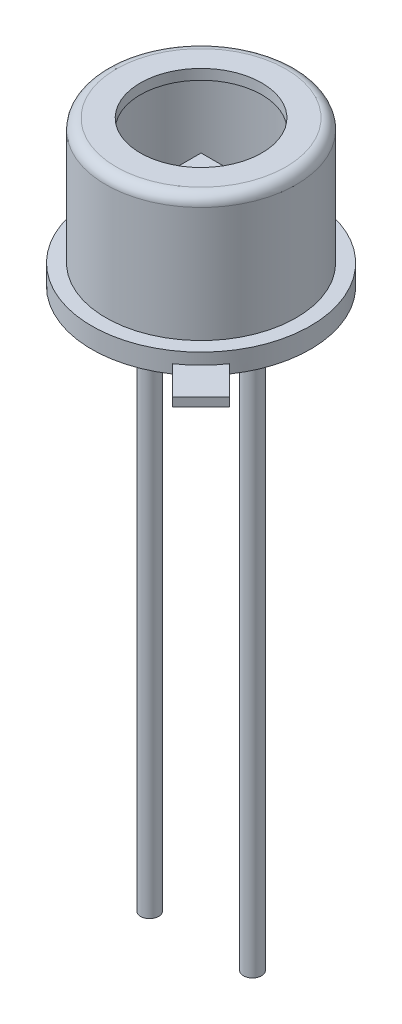
from build123d import *

# Parameters (mm, degrees)
SKETCH2_R           = 2.7
BOSS_EXTRUDE1_DEPTH = 0.246
BOSS_EXTRUDE2_START = -2.3
SKETCH3_W           = 1.1
SKETCH3_H           = 1.1
BOSS_EXTRUDE2_DEPTH = 0.05
BOSS_EXTRUDE7_DEPTH = 0.22
SKETCH5_R           = 0.225
BOSS_EXTRUDE8_DEPTH = 14


with BuildPart() as part:
    # Sketch1 → Revolve-Thin2 (revolve)
    with BuildSketch(Plane.XY):
        with BuildLine():
            Line((2.7, 0), (2.7, 0.5))
            Line((2.7, 0.5), (2.35, 0.5))
            Line((2.35, 0.5), (2.35, 3.346))
            ThreePointArc((2.35, 3.346), (2.275605122, 3.525605122), (2.096, 3.6))
            Line((2.096, 3.6), (1.5, 3.6))
            Line((1.5, 3.6), (1.5, 3.346))
            Line((1.5, 3.346), (2.096, 3.346))
            Line((2.096, 3.346), (2.096, 0.246))
            Line((2.096, 0.246), (2.446, 0.246))
            Line((2.446, 0.246), (2.446, 0))
            Line((2.446, 0), (2.7, 0))
        make_face()
    revolve(axis=Axis((0, 0, 0), (0, 1, 0)))

    # Sketch2 → Boss-Extrude1 (add)
    with BuildSketch(Plane.XZ):
        Circle(SKETCH2_R)
    extrude(amount=-BOSS_EXTRUDE1_DEPTH)

    # Sketch10 → Boss-Extrude7 (add)
    with BuildSketch(Plane.XZ):
        Polygon((1.522612913, 2.229719695), (2.229719695, 1.522612913), (2.936826476, 2.229719695), (2.229719695, 2.936826476), align=None)
    extrude(amount=-BOSS_EXTRUDE7_DEPTH)

    # Sketch5 → Boss-Extrude8 (add)
    with BuildSketch(Plane.XZ):
        with Locations((1.27, 0)):
            Circle(SKETCH5_R)
        with Locations((-1.27, 0)):
            Circle(SKETCH5_R)
    extrude(amount=BOSS_EXTRUDE8_DEPTH)


with BuildPart() as body_2:
    # Sketch3 → Boss-Extrude2 (new body)
    with BuildSketch(Plane.XZ.offset(BOSS_EXTRUDE2_START)):
        Rectangle(SKETCH3_W, SKETCH3_H)
    extrude(amount=BOSS_EXTRUDE2_DEPTH)


solid = Compound([part.part, body_2.part])
